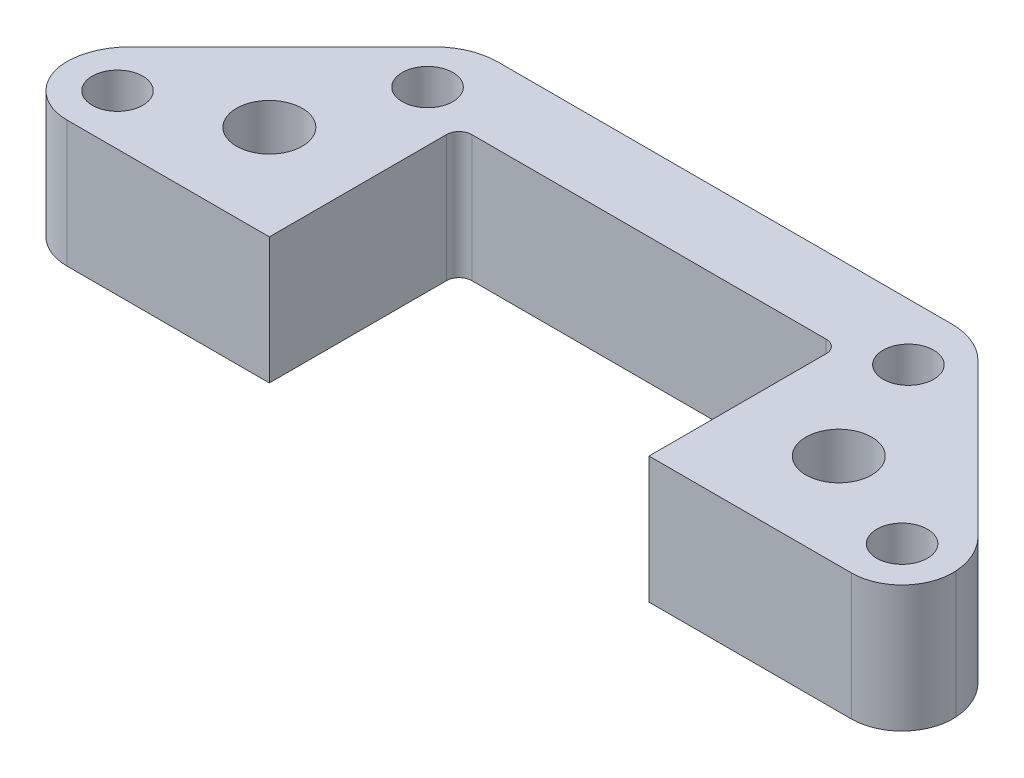
from build123d import *

# Parameters (mm, degrees)
ESQUISSE1_R             = 2.6
BOSS_EXTRU_1_DEPTH      = 10
ESQUISSE7_R             = 5.1
ENL_V_MAT_EXTRU_4_DEPTH = 5.4
ESQUISSE4_R             = 2
ENL_V_MAT_EXTRU_2_DEPTH = 10
ENL_V_MAT_EXTRU_3_DEPTH = 11
CONG_1_R                = 5
CONG_2_R                = 4


with BuildPart() as part:
    # Esquisse1 → Boss.-Extru.1 (new body)
    with BuildSketch(Plane(origin=(0, 0, 0), x_dir=(1, 0, 0), z_dir=(0, 1, 0))):
        Polygon((-20, 21), (20, 21), (35, 6), (35, 0), (15, 0), (15, 14), (14, 15), (-14, 15), (-15, 14), (-15, 0), (-35, 0), (-35, 6), align=None)
        with Locations((-22.5, 7.5)):
            Circle(ESQUISSE1_R, mode=Mode.SUBTRACT)
        with Locations((22.5, 7.5)):
            Circle(ESQUISSE1_R, mode=Mode.SUBTRACT)
    extrude(amount=BOSS_EXTRU_1_DEPTH)

    # Esquisse7 → Enlèv. mat.-Extru.4 (cut)
    with BuildSketch(Plane.XZ):
        with Locations((22.5, -7.5)):
            Circle(ESQUISSE7_R)
        with Locations((-22.5, -7.5)):
            Circle(ESQUISSE7_R)
    extrude(amount=-ENL_V_MAT_EXTRU_4_DEPTH, mode=Mode.SUBTRACT)

    # Esquisse4 → Enlèv. mat.-Extru.2 (cut)
    with BuildSketch(Plane.XZ):
        with Locations((19, -16.5)):
            Circle(ESQUISSE4_R)
        with Locations((-19, -16.5)):
            Circle(ESQUISSE4_R)
        with Locations((-31, -4)):
            Circle(ESQUISSE4_R)
        with Locations((31, -4)):
            Circle(ESQUISSE4_R)
    extrude(amount=-ENL_V_MAT_EXTRU_2_DEPTH, mode=Mode.SUBTRACT)

    # Esquisse5 → Enlèv. mat.-Extru.3 (cut, through all)
    with BuildSketch(Plane(origin=(0, 10, 0), x_dir=(1, 0, 0), z_dir=(0, 1, 0))):
        with BuildLine():
            Line((15, 14), (14, 14))
            Line((14, 14), (14, 15))
            ThreePointArc((14, 15), (14.707106781, 14.707106781), (15, 14))
        make_face()
        with BuildLine():
            Line((-14, 14), (-14, 15))
            ThreePointArc((-14, 15), (-14.707106781, 14.707106781), (-15, 14))
            Line((-15, 14), (-14, 14))
        make_face()
    extrude(amount=-ENL_V_MAT_EXTRU_3_DEPTH, mode=Mode.SUBTRACT)

    # Congé1
    cong_1_edges = [part.edges().sort_by_distance(p)[0] for p in [
        (-35, 5, -6),
        (-20, 5, -21),
        (20, 5, -21),
        (35, 5, -6),
    ]]
    fillet(cong_1_edges, radius=CONG_1_R)

    # Congé2
    cong_2_edges = [part.edges().sort_by_distance(p)[0] for p in [
        (35, 5, 0),
        (-35, 5, 0),
    ]]
    fillet(cong_2_edges, radius=CONG_2_R)


solid = part.part
